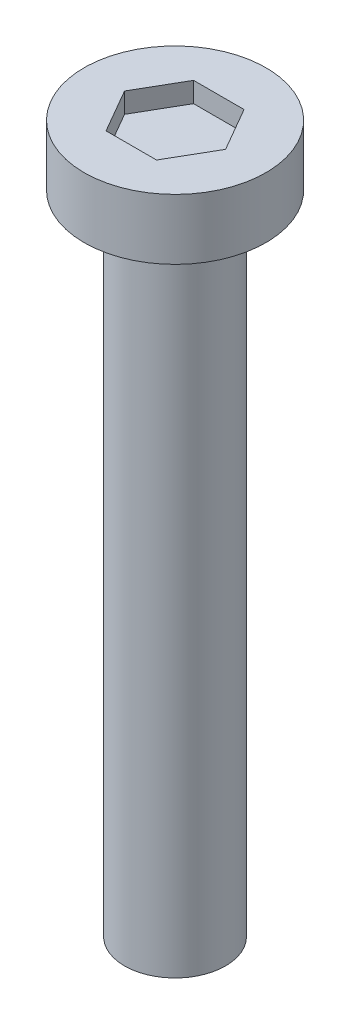
from build123d import *

# Parameters (mm, degrees)
SKETCH1_R           = 1.25
BOSS_EXTRUDE1_DEPTH = 16
SKETCH4_R           = 2.25
BOSS_EXTRUDE2_DEPTH = 1.5
CUT_EXTRUDE1_DEPTH  = 0.5


with BuildPart() as part:
    # Sketch1 → Boss-Extrude1 (new body)
    with BuildSketch(Plane(origin=(0, 0, 0), x_dir=(1, 0, 0), z_dir=(0, 1, 0))):
        Circle(SKETCH1_R)
    extrude(amount=BOSS_EXTRUDE1_DEPTH)

    # Sketch4 → Boss-Extrude2 (add)
    with BuildSketch(Plane(origin=(0, 16, 0), x_dir=(1, 0, 0), z_dir=(0, 1, 0))):
        Circle(SKETCH4_R)
    extrude(amount=BOSS_EXTRUDE2_DEPTH)

    # Sketch5 → Cut-Extrude1 (cut)
    with BuildSketch(Plane(origin=(0, 17.5, 0), x_dir=(1, 0, 0), z_dir=(0, 1, 0))):
        Polygon((1.25, 0), (0.625, 1.082531755), (-0.625, 1.082531755), (-1.25, 0), (-0.625, -1.082531755), (0.625, -1.082531755), align=None)
    extrude(amount=-CUT_EXTRUDE1_DEPTH, mode=Mode.SUBTRACT)


solid = part.part
